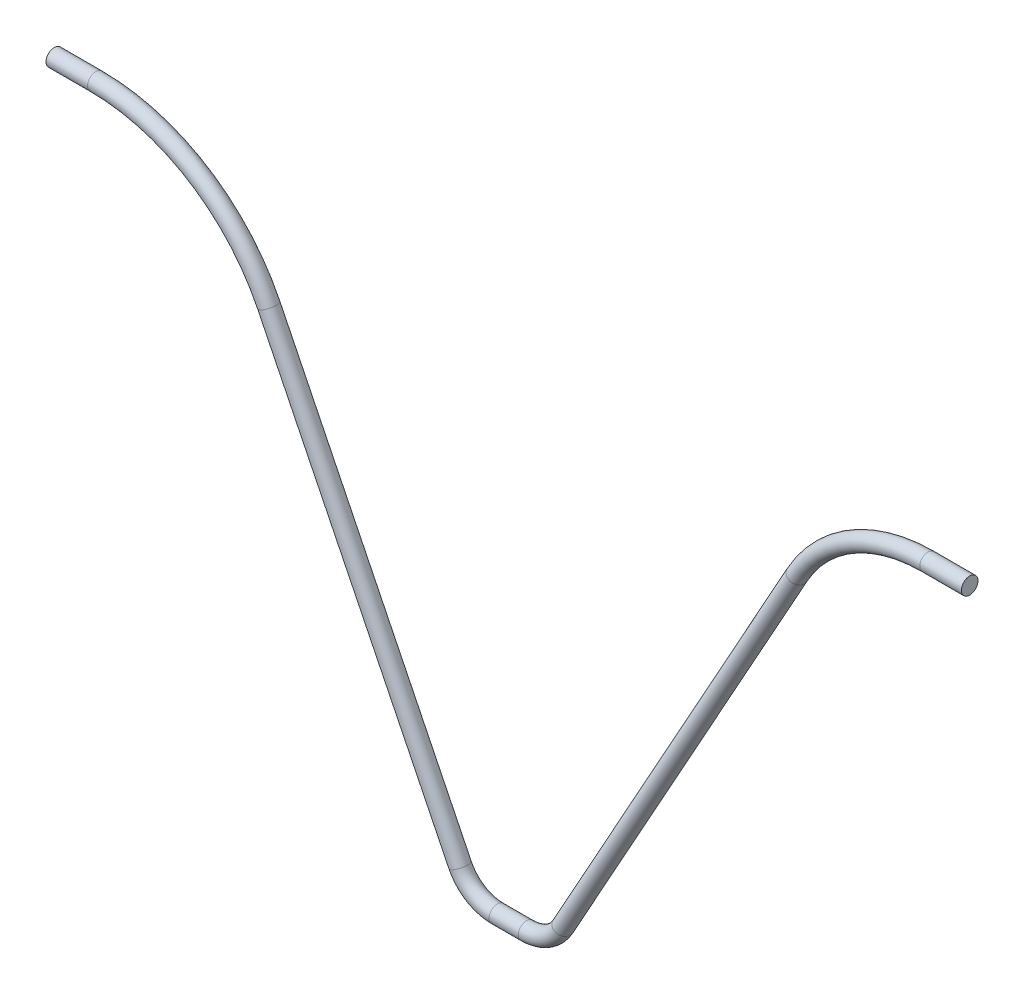
from build123d import *

# Parameters (mm, degrees)
SWEEP1_PROFILE_R = 2


with BuildPart() as part:
    # Sweep1: sweep along a path in Sketch1
    with BuildLine(Plane.XY) as sweep1_path:
        Line((-110, 81), (-100, 81))
        ThreePointArc((-100, 81), (-75.524282167, 74.001868719), (-58.447366281, 55.122950618))
        Line((-58.447366281, 55.122950618), (-12.474544991, -38.411070415))
        ThreePointArc((-12.474544991, -38.411070415), (-8.786269755, -42.4885424), (-3.5, -44))
        Line((-3.5, -44), (3.5, -44))
        ThreePointArc((3.5, -44), (8.571958407, -42.618308298), (12.242340246, -38.855047583))
        Line((12.242340246, -38.855047583), (68.512779326, 62.469463831))
        ThreePointArc((68.512779326, 62.469463831), (81.732365804, 76.023571456), (100, 81))
        Line((100, 81), (110, 81))
    # Sweep1 profile (on start of the path) → Sweep1 (sweep)
    with BuildSketch(Plane(origin=(-110, 81, 0), x_dir=(0, 0, 1), z_dir=(1, 0, 0))):
        Circle(SWEEP1_PROFILE_R)
    sweep(path=sweep1_path.line)


solid = part.part
